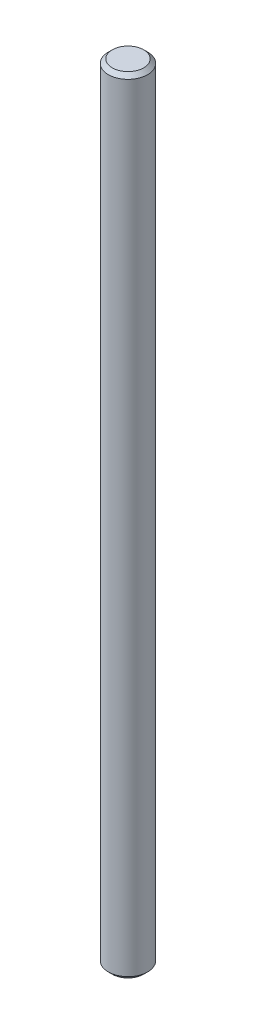
from build123d import *

# Parameters (mm, degrees)
ESQUISSE1_R        = 5
BOSS_EXTRU_1_DEPTH = 200
CHANFREIN1_SIZE    = 1


with BuildPart() as part:
    # Esquisse1 → Boss.-Extru.1 (new body)
    with BuildSketch(Plane(origin=(0, 0, 0), x_dir=(1, 0, 0), z_dir=(0, 1, 0))):
        Circle(ESQUISSE1_R)
    extrude(amount=BOSS_EXTRU_1_DEPTH)

    # Chanfrein1
    chanfrein1_edges = [part.edges().sort_by_distance(p)[0] for p in [
        (-5, 0, 0),
        (-5, 200, 0),
    ]]
    chamfer(chanfrein1_edges, length=CHANFREIN1_SIZE)


solid = part.part
